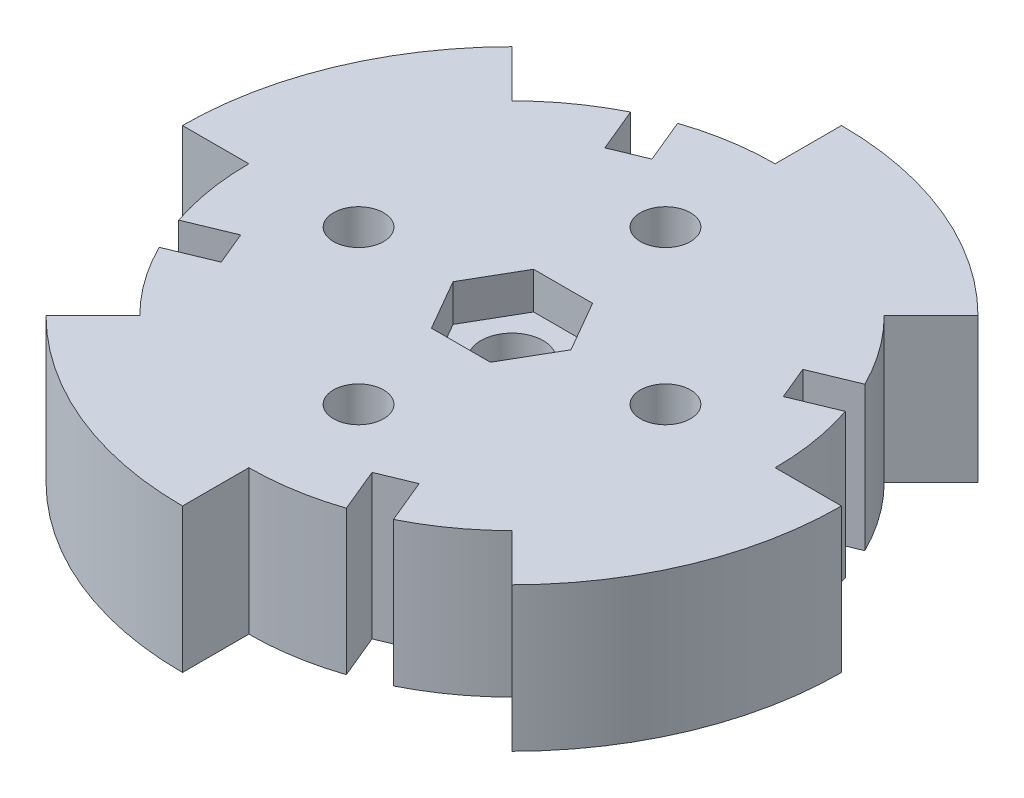
from build123d import *

# Parameters (mm, degrees)
SKETCH2_R                      = 27.42
BOSS_EXTRUDE1_DEPTH            = 12
CUT_EXTRUDE1_DEPTH             = 13
SKETCH3_R                      = 2.085
CUT_EXTRUDE2_DEPTH             = 13
CIRPATTERN1_COUNT              = 4
CUT_EXTRUDE4_DEPTH             = 13
CIRPATTERN2_COUNT              = 4
F_6_0_204_DIAMETER_HOLE1_D     = 5.1816
F_6_0_204_DIAMETER_HOLE1_DEPTH = 12
F_6_0_204_DIAMETER_HOLE1_TIP   = 1.556709692
CUT_EXTRUDE5_DEPTH             = 3.08


with BuildPart() as part:
    # Sketch2 → Boss-Extrude1 (new body)
    with BuildSketch(Plane(origin=(0, 0, 0), x_dir=(1, 0, 0), z_dir=(0, 1, 0))):
        Circle(SKETCH2_R)
    extrude(amount=BOSS_EXTRUDE1_DEPTH)

    # Sketch1 → Cut-Extrude1 (cut, through all)
    with BuildSketch(Plane(origin=(0, 0, 0), x_dir=(1, 0, 0), z_dir=(0, 1, 0))):
        with BuildLine():
            Line((0, 21.9), (0, 27.42))
            ThreePointArc((0, 27.42), (-10.493179715, 25.332776781), (-19.38886794, 19.38886794))
            Line((-19.38886794, 19.38886794), (-15.485638508, 15.485638508))
            ThreePointArc((-15.485638508, 15.485638508), (-8.380767169, 20.232961762), (0, 21.9))
        make_face()
        with BuildLine():
            Line((0, -21.9), (0, -27.42))
            ThreePointArc((0, -27.42), (10.493179715, -25.332776781), (19.38886794, -19.38886794))
            Line((19.38886794, -19.38886794), (15.485638508, -15.485638508))
            ThreePointArc((15.485638508, -15.485638508), (8.380767169, -20.232961762), (0, -21.9))
        make_face()
        with BuildLine():
            Line((21.9, 0), (27.42, 0))
            ThreePointArc((27.42, 0), (25.332776781, 10.493179715), (19.38886794, 19.38886794))
            Line((19.38886794, 19.38886794), (15.485638508, 15.485638508))
            ThreePointArc((15.485638508, 15.485638508), (20.232961762, 8.380767169), (21.9, 0))
        make_face()
        with BuildLine():
            Line((-21.9, 0), (-27.42, 0))
            ThreePointArc((-27.42, 0), (-25.332776781, -10.493179715), (-19.38886794, -19.38886794))
            Line((-19.38886794, -19.38886794), (-15.485638508, -15.485638508))
            ThreePointArc((-15.485638508, -15.485638508), (-20.232961762, -8.380767169), (-21.9, 0))
        make_face()
    extrude(amount=CUT_EXTRUDE1_DEPTH, mode=Mode.SUBTRACT)

    # Sketch3 → Cut-Extrude2 (cut, through all)
    with BuildSketch(Plane(origin=(0, 12, 0), x_dir=(1, 0, 0), z_dir=(0, 1, 0))):
        with Locations((12.77, 0)):
            Circle(SKETCH3_R)
    cut_extrude2 = extrude(amount=-CUT_EXTRUDE2_DEPTH, mode=Mode.SUBTRACT)

    # CirPattern1: Cut-Extrude2 ×4 about axis
    cirpattern1_axis = Axis((0, 0, 0), (0, 1, 0))
    for i in range(1, CIRPATTERN1_COUNT):
        add(cut_extrude2.rotate(cirpattern1_axis, i * 360 / CIRPATTERN1_COUNT), mode=Mode.SUBTRACT)

    # Sketch5 → Cut-Extrude4 (cut, through all)
    with BuildSketch(Plane(origin=(0, 12, 0), x_dir=(1, 0, 0), z_dir=(0, 1, 0))):
        Polygon((-5.464214141, 17.11146878), (-7.413599954, 21.81770245), (-10.185238552, 20.669652153), (-8.235852738, 15.963418483), (-6.850033439, 16.537443632), align=None)
    cut_extrude4 = extrude(amount=-CUT_EXTRUDE4_DEPTH, mode=Mode.SUBTRACT)

    # CirPattern2: Cut-Extrude4 ×4 about axis
    cirpattern2_axis = Axis((0, 0, 0), (0, 1, 0))
    for i in range(1, CIRPATTERN2_COUNT):
        add(cut_extrude4.rotate(cirpattern2_axis, i * 360 / CIRPATTERN2_COUNT), mode=Mode.SUBTRACT)

    # #6 (0.204) Diameter Hole1
    with Locations(Plane(origin=(0, 12, 0), x_dir=(1, 0, 0), z_dir=(0, 1, 0))):
        with Locations((0, 0)):
            Hole(F_6_0_204_DIAMETER_HOLE1_D / 2, depth=F_6_0_204_DIAMETER_HOLE1_DEPTH)
            with Locations((0, 0, -(F_6_0_204_DIAMETER_HOLE1_DEPTH + F_6_0_204_DIAMETER_HOLE1_TIP / 2))):  # 118° drill point
                Cone(0, F_6_0_204_DIAMETER_HOLE1_D / 2, F_6_0_204_DIAMETER_HOLE1_TIP, mode=Mode.SUBTRACT)

    # Sketch8 → Cut-Extrude5 (cut)
    with BuildSketch(Plane(origin=(0, 12, 0), x_dir=(1, 0, 0), z_dir=(0, 1, 0))):
        Polygon((2.453738644, -4.25), (4.907477288, 0), (2.453738644, 4.25), (-2.453738644, 4.25), (-4.907477288, 0), (-2.453738644, -4.25), align=None)
    extrude(amount=-CUT_EXTRUDE5_DEPTH, mode=Mode.SUBTRACT)


solid = part.part
